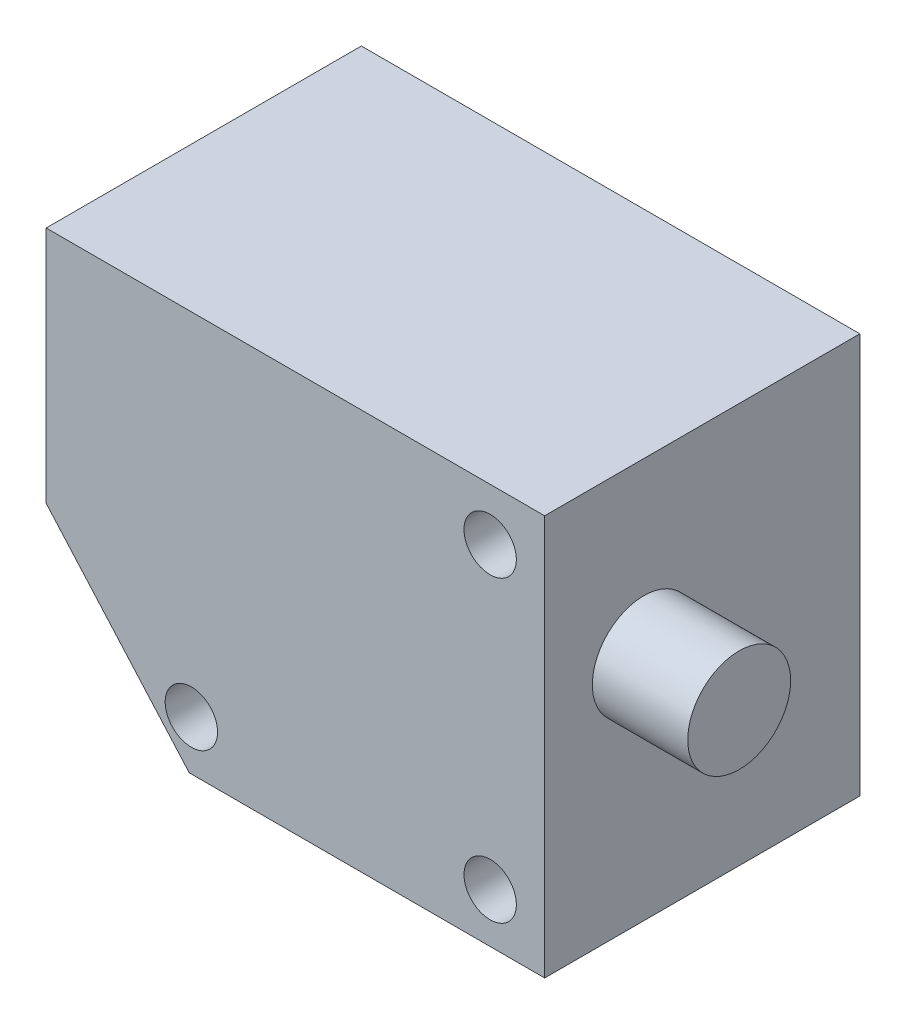
from build123d import *

# Parameters (mm, degrees)
ESBO_O1_W                                            = 53.3
ESBO_O1_H                                            = 33.7
RESSALTO_EXTRUS_O1_DEPTH                             = 21.4
CORTE_EXTRUS_O1_DEPTH                                = 34.7
ESBO_O3_R                                            = 5.5
RESSALTO_EXTRUS_O2_DEPTH                             = 10.2
ESBO_O4_R                                            = 5.5
RESSALTO_EXTRUS_O3_DEPTH                             = 4
REBAIXO_PARA_PARAFUSO_DE_M_QUINA_COM_CAB_D           = 2.9
REBAIXO_PARA_PARAFUSO_DE_M_QUINA_COM_CAB_CBORE_D     = 5.6
REBAIXO_PARA_PARAFUSO_DE_M_QUINA_COM_CAB_CBORE_DEPTH = 4.39


with BuildPart() as part:
    # Esboço1 → Ressalto-extrusão1 (new body, symmetric)
    with BuildSketch(Plane(origin=(0, 0, 0), x_dir=(1, 0, 0), z_dir=(0, 1, 0))):
        Rectangle(ESBO_O1_W, ESBO_O1_H)
    extrude(amount=RESSALTO_EXTRUS_O1_DEPTH, both=True)

    # Esboço2 → Corte-extrusão1 (cut, through all)
    with BuildSketch(Plane.XY.offset(16.85)):
        Polygon((-26.65, -21.4), (-11.35, -21.4), (-26.65, -4.093353878), align=None)
    extrude(amount=-CORTE_EXTRUS_O1_DEPTH, mode=Mode.SUBTRACT)

    # Esboço3 → Ressalto-extrusão2 (add)
    with BuildSketch(Plane(origin=(26.65, 0, 0), x_dir=(0, 0, -1), z_dir=(1, 0, 0))):
        with Locations((-6.25, 3.2)):
            Circle(ESBO_O3_R)
    extrude(amount=RESSALTO_EXTRUS_O2_DEPTH)

    # Esboço4 → Ressalto-extrusão3 (add)
    with BuildSketch(Plane.ZY.offset(26.65)):
        with Locations((6.25, 3.2)):
            Circle(ESBO_O4_R)
    extrude(amount=RESSALTO_EXTRUS_O3_DEPTH)

    # Rebaixo para parafuso de máquina com cabeça panela de M31 (through all)
    with Locations(Plane.XY.offset(16.85)):
        with Locations((20.825, 15.825), (20.825, -16.125), (-11.125, -16.125)):
            CounterBoreHole(REBAIXO_PARA_PARAFUSO_DE_M_QUINA_COM_CAB_D / 2, REBAIXO_PARA_PARAFUSO_DE_M_QUINA_COM_CAB_CBORE_D / 2, REBAIXO_PARA_PARAFUSO_DE_M_QUINA_COM_CAB_CBORE_DEPTH)


solid = part.part
